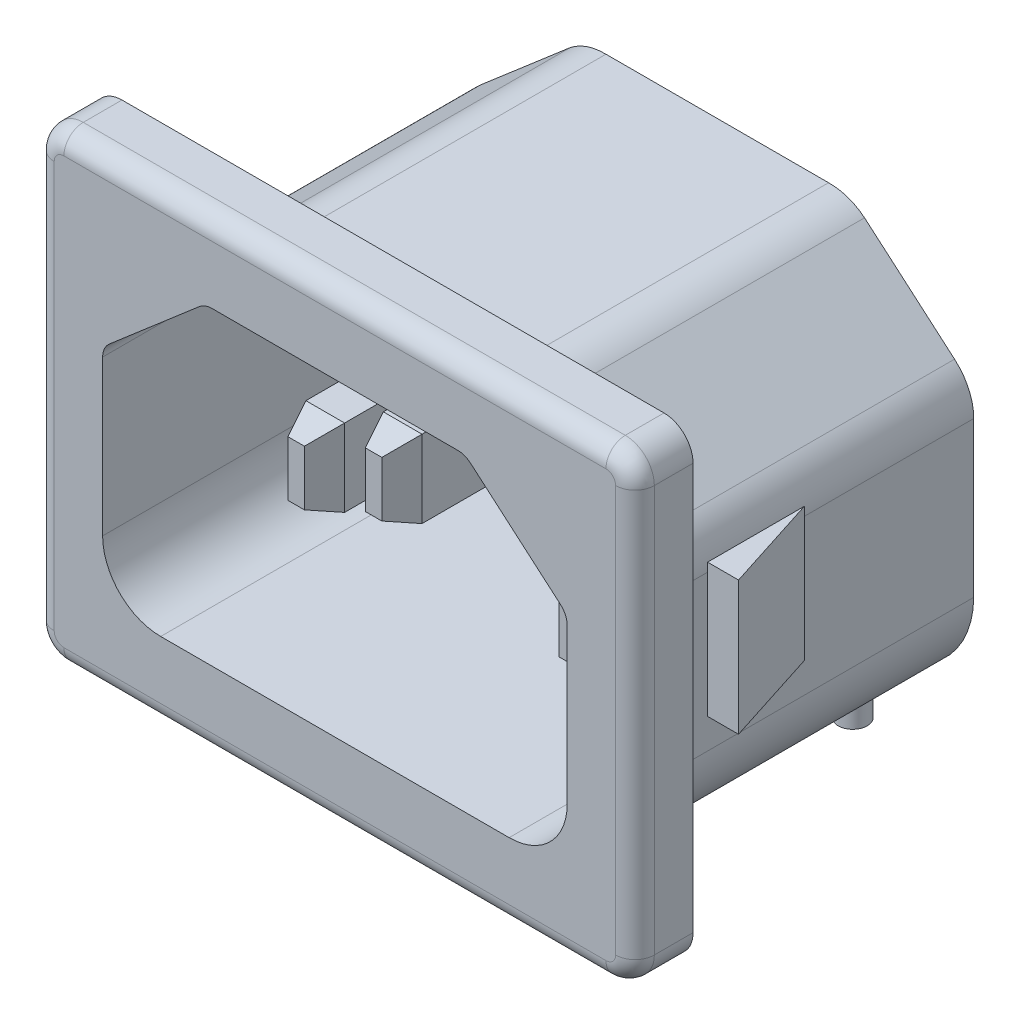
from build123d import *

# Parameters (mm, degrees)
EXTRUDE1_DEPTH         = 19.75
CUT_EXTRUDE1_DEPTH     = 17
SKETCH3_OUTSIDE_W      = 41.78
SKETCH3_OUTSIDE_H      = 34.78
CUT_EXTRUDE2_DEPTH     = 16.75
SKETCH4_W              = 2
SKETCH4_H              = 4
EXTRUDE2_DEPTH         = 15
SKETCH5_W              = 2
SKETCH5_H              = 4
CUT_EXTRUDE3_DEPTH     = 3
CHAMFER1_SIZE          = 1.5
CHAMFER1_SIZE2         = 0.575796053
CHAMFER1_PART_2_SIZE   = 1.5
CHAMFER1_PART_2_SIZE2  = 0.575796053
CHAMFER1_PART_3_SIZE   = 1.5
CHAMFER1_PART_3_SIZE2  = 0.575796053
CHAMFER1_PART_4_SIZE   = 1.5
CHAMFER1_PART_4_SIZE2  = 0.575796053
CHAMFER1_PART_5_SIZE   = 1.5
CHAMFER1_PART_5_SIZE2  = 0.575796053
CHAMFER1_PART_6_SIZE   = 1.5
CHAMFER1_PART_6_SIZE2  = 0.575796053
CHAMFER1_PART_7_SIZE   = 1.5
CHAMFER1_PART_7_SIZE2  = 0.575796053
CHAMFER1_PART_8_SIZE   = 1.5
CHAMFER1_PART_8_SIZE2  = 0.575796053
CHAMFER1_PART_9_SIZE   = 1.5
CHAMFER1_PART_9_SIZE2  = 0.575796053
CHAMFER1_PART_10_SIZE  = 1.5
CHAMFER1_PART_10_SIZE2 = 0.575796053
CHAMFER1_PART_11_SIZE  = 1.5
CHAMFER1_PART_11_SIZE2 = 0.575796053
CHAMFER1_PART_12_SIZE  = 1.5
CHAMFER1_PART_12_SIZE2 = 0.575796053
FILLET1_R              = 1
EXTRUDE3_DEPTH         = 3.45
SKETCH7_W              = 4
SKETCH7_H              = 15
SKETCH7_H_2            = 11
EXTRUDE4_DEPTH         = 2
SKETCH8_R              = 0.75
EXTRUDE5_DEPTH         = 4.2


with BuildPart() as part:
    # Sketch1 → Extrude1 (new body)
    with BuildSketch(Plane.XY):
        with BuildLine():
            Line((-14, -12), (14, -12))
            ThreePointArc((14, -12), (15.060660172, -11.560660172), (15.5, -10.5))
            Line((15.5, -10.5), (15.5, 10.5))
            ThreePointArc((15.5, 10.5), (15.060660172, 11.560660172), (14, 12))
            Line((14, 12), (-14, 12))
            ThreePointArc((-14, 12), (-15.060660172, 11.560660172), (-15.5, 10.5))
            Line((-15.5, 10.5), (-15.5, -10.5))
            ThreePointArc((-15.5, -10.5), (-15.060660172, -11.560660172), (-14, -12))
        make_face()
    extrude(amount=EXTRUDE1_DEPTH)

    # Sketch2 → Cut-Extrude1 (cut)
    with BuildSketch(Plane.XY.offset(19.75)):
        with BuildLine():
            Line((-12, 3), (-12, -5))
            ThreePointArc((-12, -5), (-11.121320344, -7.121320344), (-9, -8))
            Line((-9, -8), (9, -8))
            ThreePointArc((9, -8), (11.121320344, -7.121320344), (12, -5))
            Line((12, -5), (12, 3))
            ThreePointArc((12, 3), (11.908882001, 3.417053364), (11.652132983, 3.758104592))
            Line((11.652132983, 3.758104592), (7.002132983, 7.758104592))
            ThreePointArc((7.002132983, 7.758104592), (6.697775364, 7.937577888), (6.35, 8))
            Line((6.35, 8), (-6.35, 8))
            ThreePointArc((-6.35, 8), (-6.697775364, 7.937577888), (-7.002132983, 7.758104592))
            Line((-7.002132983, 7.758104592), (-11.652132983, 3.758104592))
            ThreePointArc((-11.652132983, 3.758104592), (-11.908882001, 3.417053364), (-12, 3))
        make_face()
    extrude(amount=-CUT_EXTRUDE1_DEPTH, mode=Mode.SUBTRACT)

    # Sketch3 outside → Cut-Extrude2 (cut)
    with BuildSketch(Plane(origin=(0, 0, 0), x_dir=(-1, 0, 0), z_dir=(0, 0, -1))):
        Rectangle(SKETCH3_OUTSIDE_W, SKETCH3_OUTSIDE_H)
        with BuildLine():
            Line((13.25, 3), (13.25, -5))
            ThreePointArc((13.25, -5), (11.811910569, -8.397190887), (8.4, -9.8))
            Line((8.4, -9.8), (-8.4, -9.8))
            ThreePointArc((-8.4, -9.8), (-11.811910569, -8.397190887), (-13.25, -5))
            Line((-13.25, -5), (-13.25, 3))
            ThreePointArc((-13.25, 3), (-12.990313702, 4.188602088), (-12.258579001, 5.160598088))
            Line((-12.258579001, 5.160598088), (-7.608579001, 9.160598088))
            ThreePointArc((-7.608579001, 9.160598088), (-6.736153383, 9.645587911), (-5.75, 9.8))
            Line((-5.75, 9.8), (5.75, 9.8))
            ThreePointArc((5.75, 9.8), (6.736153383, 9.645587911), (7.608579001, 9.160598088))
            Line((7.608579001, 9.160598088), (12.258579001, 5.160598088))
            ThreePointArc((12.258579001, 5.160598088), (12.990313702, 4.188602088), (13.25, 3))
        make_face(mode=Mode.SUBTRACT)
    extrude(amount=-CUT_EXTRUDE2_DEPTH, mode=Mode.SUBTRACT)

    # Sketch4 → Extrude2 (add)
    with BuildSketch(Plane.XY.offset(2.75)):
        with Locations((0, 2.3)):
            Rectangle(SKETCH4_W, SKETCH4_H)
        with Locations((-7, -2.2)):
            Rectangle(SKETCH4_W, SKETCH4_H)
        with Locations((7, -2.2)):
            Rectangle(SKETCH4_W, SKETCH4_H)
    extrude(amount=EXTRUDE2_DEPTH)

    # Sketch5 → Cut-Extrude3 (cut)
    with BuildSketch(Plane.XY.offset(17.75)):
        with Locations((7, -2.2)):
            Rectangle(SKETCH5_W, SKETCH5_H)
        with Locations((-7, -2.2)):
            Rectangle(SKETCH5_W, SKETCH5_H)
    extrude(amount=-CUT_EXTRUDE3_DEPTH, mode=Mode.SUBTRACT)

    # Chamfer1
    chamfer1_edges = [part.edges().sort_by_distance(p)[0] for p in [
        (0, 4.3, 17.75),
    ]]
    chamfer1_side = [part.faces().sort_by_distance(p)[0] for p in [
        (0, 4.3, 10.25),
    ]]
    chamfer(chamfer1_edges, length=CHAMFER1_SIZE, length2=CHAMFER1_SIZE2, reference=chamfer1_side[0])

    # Chamfer1 part 2
    chamfer1_part_2_edges = [part.edges().sort_by_distance(p)[0] for p in [
        (-1, 2.3, 17.75),
    ]]
    chamfer1_part_2_side = [part.faces().sort_by_distance(p)[0] for p in [
        (-1, 2.3, 10.25),
    ]]
    chamfer(chamfer1_part_2_edges, length=CHAMFER1_PART_2_SIZE, length2=CHAMFER1_PART_2_SIZE2, reference=chamfer1_part_2_side[0])

    # Chamfer1 part 3
    chamfer1_part_3_edges = [part.edges().sort_by_distance(p)[0] for p in [
        (0, 0.3, 17.75),
    ]]
    chamfer1_part_3_side = [part.faces().sort_by_distance(p)[0] for p in [
        (0, 0.3, 10.25),
    ]]
    chamfer(chamfer1_part_3_edges, length=CHAMFER1_PART_3_SIZE, length2=CHAMFER1_PART_3_SIZE2, reference=chamfer1_part_3_side[0])

    # Chamfer1 part 4
    chamfer1_part_4_edges = [part.edges().sort_by_distance(p)[0] for p in [
        (1, 2.3, 17.75),
    ]]
    chamfer1_part_4_side = [part.faces().sort_by_distance(p)[0] for p in [
        (1, 2.3, 10.25),
    ]]
    chamfer(chamfer1_part_4_edges, length=CHAMFER1_PART_4_SIZE, length2=CHAMFER1_PART_4_SIZE2, reference=chamfer1_part_4_side[0])

    # Chamfer1 part 5
    chamfer1_part_5_edges = [part.edges().sort_by_distance(p)[0] for p in [
        (7, -4.2, 14.75),
    ]]
    chamfer1_part_5_side = [part.faces().sort_by_distance(p)[0] for p in [
        (7, -4.2, 8.75),
    ]]
    chamfer(chamfer1_part_5_edges, length=CHAMFER1_PART_5_SIZE, length2=CHAMFER1_PART_5_SIZE2, reference=chamfer1_part_5_side[0])

    # Chamfer1 part 6
    chamfer1_part_6_edges = [part.edges().sort_by_distance(p)[0] for p in [
        (6, -2.2, 14.75),
    ]]
    chamfer1_part_6_side = [part.faces().sort_by_distance(p)[0] for p in [
        (6, -2.2, 8.75),
    ]]
    chamfer(chamfer1_part_6_edges, length=CHAMFER1_PART_6_SIZE, length2=CHAMFER1_PART_6_SIZE2, reference=chamfer1_part_6_side[0])

    # Chamfer1 part 7
    chamfer1_part_7_edges = [part.edges().sort_by_distance(p)[0] for p in [
        (7, -0.2, 14.75),
    ]]
    chamfer1_part_7_side = [part.faces().sort_by_distance(p)[0] for p in [
        (7, -0.2, 8.75),
    ]]
    chamfer(chamfer1_part_7_edges, length=CHAMFER1_PART_7_SIZE, length2=CHAMFER1_PART_7_SIZE2, reference=chamfer1_part_7_side[0])

    # Chamfer1 part 8
    chamfer1_part_8_edges = [part.edges().sort_by_distance(p)[0] for p in [
        (8, -2.2, 14.75),
    ]]
    chamfer1_part_8_side = [part.faces().sort_by_distance(p)[0] for p in [
        (8, -2.2, 8.75),
    ]]
    chamfer(chamfer1_part_8_edges, length=CHAMFER1_PART_8_SIZE, length2=CHAMFER1_PART_8_SIZE2, reference=chamfer1_part_8_side[0])

    # Chamfer1 part 9
    chamfer1_part_9_edges = [part.edges().sort_by_distance(p)[0] for p in [
        (-7, -4.2, 14.75),
    ]]
    chamfer1_part_9_side = [part.faces().sort_by_distance(p)[0] for p in [
        (-7, -4.2, 8.75),
    ]]
    chamfer(chamfer1_part_9_edges, length=CHAMFER1_PART_9_SIZE, length2=CHAMFER1_PART_9_SIZE2, reference=chamfer1_part_9_side[0])

    # Chamfer1 part 10
    chamfer1_part_10_edges = [part.edges().sort_by_distance(p)[0] for p in [
        (-8, -2.2, 14.75),
    ]]
    chamfer1_part_10_side = [part.faces().sort_by_distance(p)[0] for p in [
        (-8, -2.2, 8.75),
    ]]
    chamfer(chamfer1_part_10_edges, length=CHAMFER1_PART_10_SIZE, length2=CHAMFER1_PART_10_SIZE2, reference=chamfer1_part_10_side[0])

    # Chamfer1 part 11
    chamfer1_part_11_edges = [part.edges().sort_by_distance(p)[0] for p in [
        (-7, -0.2, 14.75),
    ]]
    chamfer1_part_11_side = [part.faces().sort_by_distance(p)[0] for p in [
        (-7, -0.2, 8.75),
    ]]
    chamfer(chamfer1_part_11_edges, length=CHAMFER1_PART_11_SIZE, length2=CHAMFER1_PART_11_SIZE2, reference=chamfer1_part_11_side[0])

    # Chamfer1 part 12
    chamfer1_part_12_edges = [part.edges().sort_by_distance(p)[0] for p in [
        (-6, -2.2, 14.75),
    ]]
    chamfer1_part_12_side = [part.faces().sort_by_distance(p)[0] for p in [
        (-6, -2.2, 8.75),
    ]]
    chamfer(chamfer1_part_12_edges, length=CHAMFER1_PART_12_SIZE, length2=CHAMFER1_PART_12_SIZE2, reference=chamfer1_part_12_side[0])

    # Fillet1
    fillet1_edges = [part.edges().sort_by_distance(p)[0] for p in [
        (-15.060660172, -11.560660172, 19.75),
        (0, -12, 19.75),
        (15.060660172, -11.560660172, 19.75),
        (15.5, 0, 19.75),
        (15.060660172, 11.560660172, 19.75),
        (0, 12, 19.75),
        (-15.060660172, 11.560660172, 19.75),
        (-15.5, 0, 19.75),
    ]]
    fillet(fillet1_edges, radius=FILLET1_R)

    # Sketch6 → Extrude3 (add, symmetric)
    with BuildSketch(Plane(origin=(0, 0, 0), x_dir=(1, 0, 0), z_dir=(0, 1, 0))):
        Polygon((13.25, -13.75), (13.25, -8.75), (14.85, -13.75), align=None)
        Polygon((-14.85, -13.75), (-13.25, -8.75), (-13.25, -13.75), align=None)
    extrude(amount=EXTRUDE3_DEPTH, both=True)

    # Sketch7 → Extrude4 (add)
    with BuildSketch(Plane(origin=(0, 0, 0), x_dir=(-1, 0, 0), z_dir=(0, 0, -1))):
        with Locations((0, -1.8)):
            Rectangle(SKETCH7_W, SKETCH7_H)
        with Locations((-7, -3.8)):
            Rectangle(SKETCH7_W, SKETCH7_H_2)
        with Locations((7, -3.8)):
            Rectangle(SKETCH7_W, SKETCH7_H_2)
    extrude(amount=EXTRUDE4_DEPTH)

    # Sketch8 → Extrude5 (add)
    with BuildSketch(Plane.XZ.offset(9.3)):
        with Locations((7, 0)):
            Circle(SKETCH8_R)
        Circle(SKETCH8_R)
        with Locations((-7, 0)):
            Circle(SKETCH8_R)
    extrude(amount=EXTRUDE5_DEPTH)


solid = part.part
